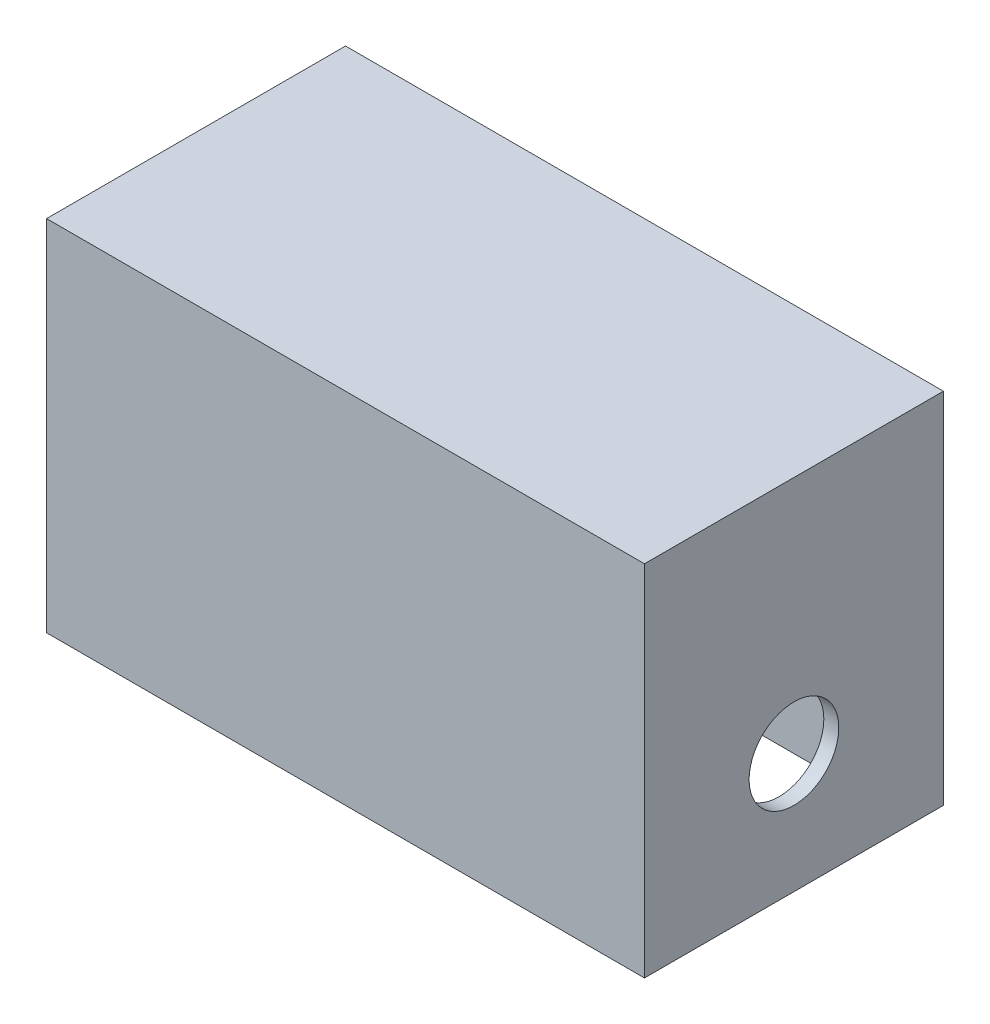
from build123d import *

# Parameters (mm, degrees)
SKETCH1_W           = 100
SKETCH1_H           = 60
BOSS_EXTRUDE1_DEPTH = 50
SKETCH2_W           = 95
SKETCH2_H           = 40
CUT_EXTRUDE1_DEPTH  = 55
SKETCH3_R           = 7.5
CUT_EXTRUDE2_DEPTH  = 101


with BuildPart() as part:
    # Sketch1 → Boss-Extrude1 (new body)
    with BuildSketch(Plane.XY):
        with Locations((50, 30)):
            Rectangle(SKETCH1_W, SKETCH1_H)
    extrude(amount=BOSS_EXTRUDE1_DEPTH)

    # Sketch2 → Cut-Extrude1 (cut)
    with BuildSketch(Plane.XZ):
        with Locations((50, 25)):
            Rectangle(SKETCH2_W, SKETCH2_H)
    extrude(amount=-CUT_EXTRUDE1_DEPTH, mode=Mode.SUBTRACT)

    # Sketch3 → Cut-Extrude2 (cut, through all)
    with BuildSketch(Plane.ZY):
        with Locations((25, 20)):
            Circle(SKETCH3_R)
    extrude(amount=-CUT_EXTRUDE2_DEPTH, mode=Mode.SUBTRACT)


solid = part.part
